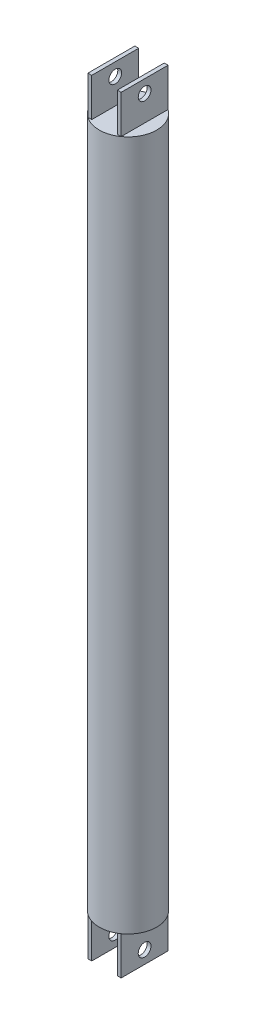
from build123d import *

# Parameters (mm, degrees)
SKETCH1_R               = 22.5
SKETCH1_R_2             = 20.5
EXTRUDE1_DEPTH          = 500
SKETCH2_R               = 22.5
EXTRUDE2_DEPTH          = 20
SKETCH3_R               = 22.5
EXTRUDE3_DEPTH          = 20
SKETCH5_W               = 3
SKETCH5_H               = 36.728735344
EXTRUDE4_DEPTH          = 30
SKETCH7_W               = 3
SKETCH7_H               = 36.728735344
EXTRUDE6_DEPTH          = 30
SKETCH8_R               = 5
CUT_EXTRUDE1_DEPTH      = 10.5
CUT_EXTRUDE1_DEPTH_BACK = 36.5
SKETCH9_R               = 5
CUT_EXTRUDE2_DEPTH      = 10.5
CUT_EXTRUDE2_DEPTH_BACK = 36.5


with BuildPart() as part:
    # Sketch1 → Extrude1 (new body)
    with BuildSketch(Plane(origin=(0, 0, 0), x_dir=(1, 0, 0), z_dir=(0, 1, 0))):
        with Locations(Location((0, 0, 0), (0, 0, 270))):  # turned: the seam where the file's is
            Circle(SKETCH1_R)
        with Locations(Location((0, 0, 0), (0, 0, 270))):  # turned: the seam where the file's is
            Circle(SKETCH1_R_2, mode=Mode.SUBTRACT)
    extrude(amount=EXTRUDE1_DEPTH)

    # Sketch2 → Extrude2 (add)
    with BuildSketch(Plane(origin=(0, 500, 0), x_dir=(-1, 0, 0), z_dir=(0, 1, 0))):
        with Locations(Location((0, 0, 0), (0, 0, 90))):  # turned: the seam where the file's is
            Circle(SKETCH2_R)
    extrude(amount=EXTRUDE2_DEPTH)

    # Sketch3 → Extrude3 (add)
    with BuildSketch(Plane.XZ):
        with Locations(Location((0, 0, 0), (0, 0, 270))):  # turned: the seam where the file's is
            Circle(SKETCH3_R)
    extrude(amount=EXTRUDE3_DEPTH)

    # Sketch5 → Extrude4 (add)
    with BuildSketch(Plane.XZ.offset(20)):
        with Locations((-11.5, 0)):
            Rectangle(SKETCH5_W, SKETCH5_H)
        with Locations((11.5, 0)):
            Rectangle(SKETCH5_W, SKETCH5_H)
    extrude(amount=EXTRUDE4_DEPTH)

    # Sketch7 → Extrude6 (add)
    with BuildSketch(Plane(origin=(0, 520, 0), x_dir=(-1, 0, 0), z_dir=(0, 1, 0))):
        with Locations((-11.5, 0)):
            Rectangle(SKETCH7_W, SKETCH7_H)
        with Locations((11.5, 0)):
            Rectangle(SKETCH7_W, SKETCH7_H)
    extrude(amount=EXTRUDE6_DEPTH)

    # Sketch8 → Cut-Extrude1 (cut, two sides)
    with BuildSketch(Plane.ZY.offset(13)) as cut_extrude1_sk:
        with Locations((0, 540)):
            Circle(SKETCH8_R)
    extrude(amount=CUT_EXTRUDE1_DEPTH, mode=Mode.SUBTRACT)
    extrude(cut_extrude1_sk.sketch, amount=-CUT_EXTRUDE1_DEPTH_BACK, mode=Mode.SUBTRACT)

    # Sketch9 → Cut-Extrude2 (cut, two sides)
    with BuildSketch(Plane.ZY.offset(13)) as cut_extrude2_sk:
        with Locations((0, -40)):
            Circle(SKETCH9_R)
    extrude(amount=CUT_EXTRUDE2_DEPTH, mode=Mode.SUBTRACT)
    extrude(cut_extrude2_sk.sketch, amount=-CUT_EXTRUDE2_DEPTH_BACK, mode=Mode.SUBTRACT)


solid = part.part
